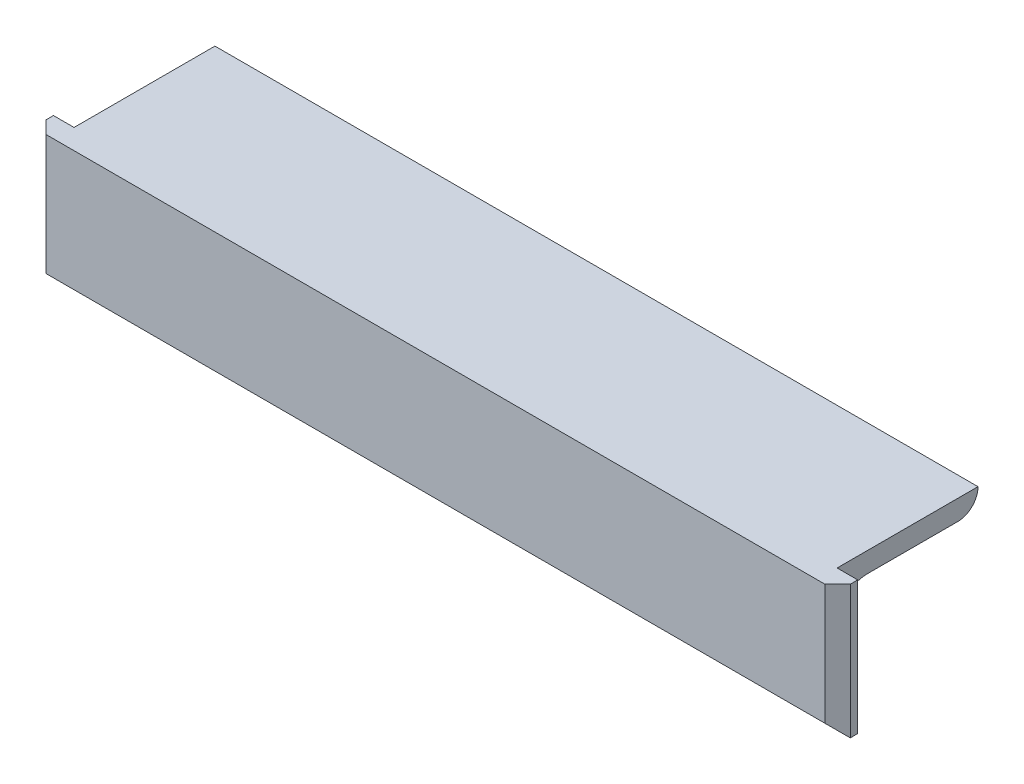
from build123d import *

# Parameters (mm, degrees)
HIERRO_ANGULAR_1_X_1_X_0_125_1_DEPTH = 126.87
CROQUIS3_W                           = 3.25
CROQUIS3_H                           = 22.225
CORTAR_EXTRUIR1_DEPTH                = 10
CROQUIS4_W                           = 126.87
CROQUIS4_H                           = 4.4
CORTAR_EXTRUIR2_DEPTH                = 10
CHAFL_N1_SIZE                        = 2
CHAFL_N2_SIZE                        = 2


with BuildPart() as part:
    # Sketch1 → Hierro angular 1 X 1 X 0.125(1) (new body)
    with BuildSketch(Plane(origin=(-63.435, 0, 0), x_dir=(0, -1, 0), z_dir=(1, 0, 0))):
        with BuildLine():
            Line((0, 0), (0, 25.4))
            Line((0, 25.4), (0.00508, 25.4))
            ThreePointArc((0.00508, 25.4), (2.246551928, 24.471551928), (3.175, 22.23008))
            Line((3.175, 22.23008), (3.175, 7.9375))
            ThreePointArc((3.175, 7.9375), (4.569903955, 4.569903955), (7.9375, 3.175))
            Line((7.9375, 3.175), (22.23008, 3.175))
            ThreePointArc((22.23008, 3.175), (24.471551928, 2.246551928), (25.4, 0.00508))
            Line((25.4, 0.00508), (25.4, 0))
            Line((25.4, 0), (0, 0))
        make_face()
    extrude(amount=HIERRO_ANGULAR_1_X_1_X_0_125_1_DEPTH)

    # Croquis3 → Cortar-Extruir1 (cut)
    with BuildSketch(Plane(origin=(0, 0, 0), x_dir=(1, 0, 0), z_dir=(0, 1, 0))):
        with Locations((-61.81, 14.2875)):
            Rectangle(CROQUIS3_W, CROQUIS3_H)
        with Locations((61.81, 14.2875)):
            Rectangle(CROQUIS3_W, CROQUIS3_H)
    extrude(amount=-CORTAR_EXTRUIR1_DEPTH, mode=Mode.SUBTRACT)

    # Croquis4 → Cortar-Extruir2 (cut)
    with BuildSketch(Plane.XY):
        with Locations((0, -23.2)):
            Rectangle(CROQUIS4_W, CROQUIS4_H)
    extrude(amount=-CORTAR_EXTRUIR2_DEPTH, mode=Mode.SUBTRACT)

    # Chaflán1
    chafl_n1_edges = [part.edges().sort_by_distance(p)[0] for p in [
        (0, -21, 0),
    ]]
    chamfer(chafl_n1_edges, length=CHAFL_N1_SIZE)

    # Chaflán2
    chafl_n2_edges = [part.edges().sort_by_distance(p)[0] for p in [
        (63.435, -9.5, 0),
        (-63.435, -9.5, 0),
    ]]
    chamfer(chafl_n2_edges, length=CHAFL_N2_SIZE)


solid = part.part
